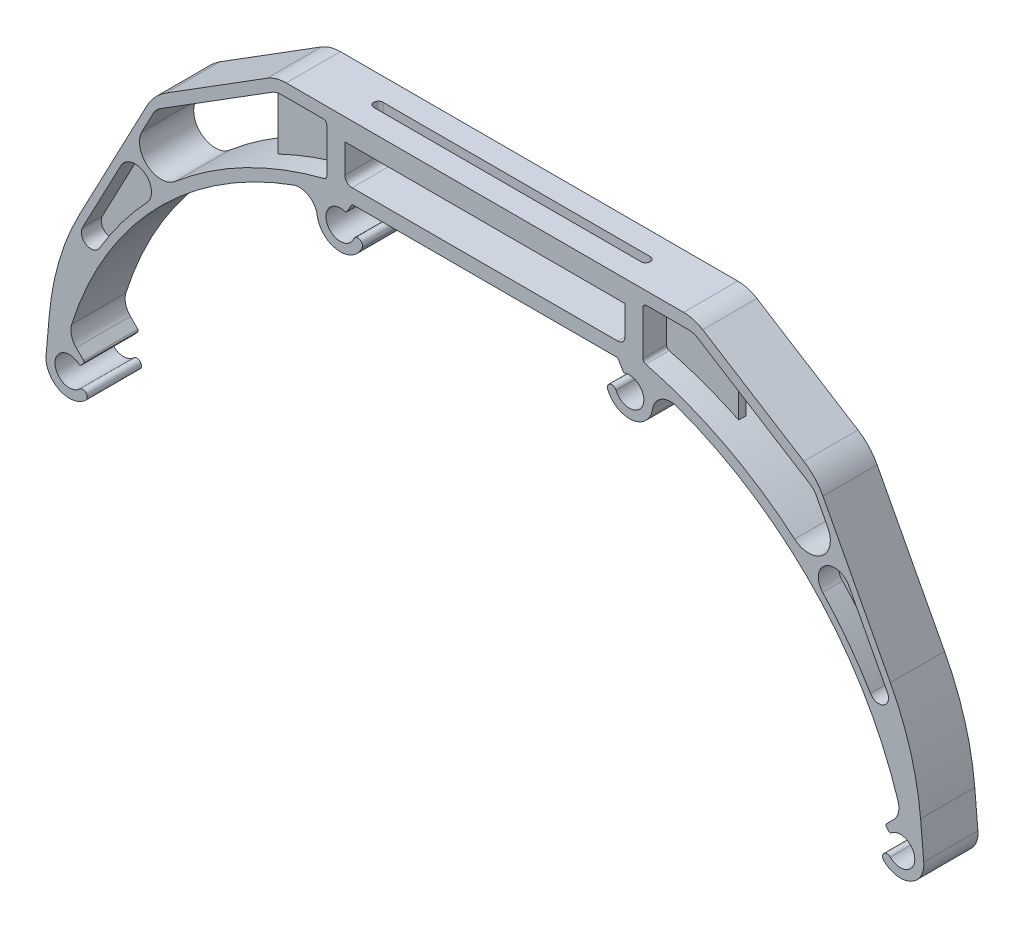
from build123d import *

# Parameters (mm, degrees)
EXTRUDE_7_DEPTH     = 15
CUT_EXTRUDE_1_DEPTH = 257.870857521
RIB_4_REACH         = 258.542
SKETCH_7_WALL_W     = 532.538559092
SKETCH_7_WALL_H     = 2
RIB_5_REACH         = 258.542
SKETCH_8_WALL_W     = 532.538559092
SKETCH_8_WALL_H     = 2
CUT_EXTRUDE_2_DEPTH = 257.870857521
CUT_EXTRUDE_3_DEPTH = 10
CUT_EXTRUDE_4_DEPTH = 257.870857521
EXTRUDE_8_DEPTH     = 2


with BuildPart() as part:
    # 草图3 → 凸台-拉伸7 (new body)
    with BuildSketch(Plane.XY):
        with BuildLine():
            Line((226.107883645, 4.564084021), (228.1313581, 6.587558476))
            ThreePointArc((228.1313581, 6.587558476), (229.452157682, 8.933123872), (229.365360937, 11.623598716))
            ThreePointArc((229.365360937, 11.623598716), (202.204022959, 54.721265071), (157.336152658, 78.846383531))
            ThreePointArc((157.336152658, 78.846383531), (156.176241581, 79.053674225), (155, 79.123092382))
            Line((155, 79.123092382), (75, 79.123092382))
            ThreePointArc((75, 79.123092382), (73.823758419, 79.053674225), (72.663847342, 78.846383531))
            ThreePointArc((72.663847342, 78.846383531), (27.795977041, 54.721265071), (0.634639063, 11.623598716))
            ThreePointArc((0.634639063, 11.623598716), (0.547842318, 8.933123872), (1.8686419, 6.587558476))
            Line((1.8686419, 6.587558476), (3.892116355, 4.564084021))
            ThreePointArc((3.892116355, 4.564084021), (4.038087075, 4.232340324), (3.921585186, 3.889136825))
            Line((3.921585186, 3.889136825), (3.278797577, 3.123092382))
            ThreePointArc((3.278797577, 3.123092382), (2.939119693, 2.946368462), (2.574022538, 3.0617655))
            ThreePointArc((2.574022538, 3.0617655), (-3.997102919, -0.152211219), (2.799416849, -2.857142857))
            ThreePointArc((2.799416849, -2.857142857), (4.567091757, -2.875182235), (4.549052379, -4.642857143))
            ThreePointArc((4.549052379, -4.642857143), (-2.777041025, -5.876907618), (-6.475265538, 0.566512328))
            Line((-6.475265538, 0.566512328), (-5.60370811, 10.528459309))
            ThreePointArc((-5.60370811, 10.528459309), (-2.837136411, 25.169145871), (2.769030559, 38.974018703))
            Line((2.769030559, 38.974018703), (21.426225279, 74.356346003))
            ThreePointArc((21.426225279, 74.356346003), (23.699524873, 77.563248735), (26.727922901, 80.069425417))
            Line((26.727922901, 80.069425417), (54.688883256, 97.596110672))
            ThreePointArc((54.688883256, 97.596110672), (57.236866172, 98.733768292), (60, 99.123092382))
            Line((60, 99.123092382), (170, 99.123092382))
            ThreePointArc((170, 99.123092382), (172.763133828, 98.733768292), (175.311116744, 97.596110672))
            Line((175.311116744, 97.596110672), (203.272077099, 80.069425417))
            ThreePointArc((203.272077099, 80.069425417), (206.300475127, 77.563248735), (208.573774721, 74.356346003))
            Line((208.573774721, 74.356346003), (227.230969441, 38.974018703))
            ThreePointArc((227.230969441, 38.974018703), (232.837136411, 25.169145871), (235.60370811, 10.528459309))
            Line((235.60370811, 10.528459309), (236.475265538, 0.566512328))
            ThreePointArc((236.475265538, 0.566512328), (232.777041025, -5.876907618), (225.450947621, -4.642857143))
            ThreePointArc((225.450947621, -4.642857143), (225.432908243, -2.875182235), (227.200583151, -2.857142857))
            ThreePointArc((227.200583151, -2.857142857), (233.997102919, -0.152211219), (227.425977462, 3.0617655))
            ThreePointArc((227.425977462, 3.0617655), (227.060880307, 2.946368462), (226.721202423, 3.123092382))
            Line((226.721202423, 3.123092382), (226.078414814, 3.889136825))
            ThreePointArc((226.078414814, 3.889136825), (225.961912925, 4.232340324), (226.107883645, 4.564084021))
        make_face()
        with BuildLine():
            Line((155, 79.123092382), (151.5, 79.123092382))
            ThreePointArc((151.5, 79.123092382), (151.75, 79.056105084), (151.933012702, 78.873092382))
            Line((151.933012702, 78.873092382), (153.208862747, 76.663255282))
            ThreePointArc((153.208862747, 76.663255282), (153.460925165, 76.447146931), (153.792778177, 76.436570515))
            ThreePointArc((153.792778177, 76.436570515), (158.62462258, 70.93131487), (151.301621364, 71.099282859))
            ThreePointArc((151.301621364, 71.099282859), (149.669687564, 71.778835706), (148.990134717, 70.146901906))
            ThreePointArc((148.990134717, 70.146901906), (155.784690615, 66.170630787), (161.428180194, 71.659505648))
            ThreePointArc((161.428180194, 71.659505648), (163.815160833, 75.214538736), (168.0781083, 75.6185384))
            ThreePointArc((168.0781083, 75.6185384), (162.752422297, 77.383187743), (157.336152658, 78.846383531))
            ThreePointArc((157.336152658, 78.846383531), (156.176241581, 79.053674225), (155, 79.123092382))
        make_face()
        with BuildLine():
            ThreePointArc((72.663847342, 78.846383531), (67.247577703, 77.383187743), (61.9218917, 75.6185384))
            ThreePointArc((61.9218917, 75.6185384), (66.184839167, 75.214538736), (68.571819806, 71.659505648))
            ThreePointArc((68.571819806, 71.659505648), (74.215309385, 66.170630787), (81.009865283, 70.146901906))
            ThreePointArc((81.009865283, 70.146901906), (80.330312436, 71.778835706), (78.698378636, 71.099282859))
            ThreePointArc((78.698378636, 71.099282859), (71.37537742, 70.93131487), (76.207221823, 76.436570515))
            ThreePointArc((76.207221823, 76.436570515), (76.539074835, 76.447146931), (76.791137253, 76.663255282))
            Line((76.791137253, 76.663255282), (78.066987298, 78.873092382))
            ThreePointArc((78.066987298, 78.873092382), (78.25, 79.056105084), (78.5, 79.123092382))
            Line((78.5, 79.123092382), (75, 79.123092382))
            ThreePointArc((75, 79.123092382), (73.823758419, 79.053674225), (72.663847342, 78.846383531))
        make_face()
    extrude(amount=EXTRUDE_7_DEPTH)

    # 草图6 → 切除-拉伸1 (cut, through all)
    with BuildSketch(Plane.XY.offset(15)):
        with BuildLine():
            ThreePointArc((58.67439973, 95.652604272), (57.292832816, 95.457942227), (56.018841358, 94.889113416))
            Line((56.018841358, 94.889113416), (51.236866172, 91.891642195))
            Line((51.236866172, 91.891642195), (51.236866172, 74.437432673))
            ThreePointArc((51.236866172, 74.437432673), (60.685741856, 78.429836873), (70.484678821, 81.463214092))
            ThreePointArc((70.484678821, 81.463214092), (71.026743583, 81.818757299), (71.236866172, 82.432022066))
            Line((71.236866172, 82.432022066), (71.236866172, 94.652604272))
            ThreePointArc((71.236866172, 94.652604272), (70.943972953, 95.359711053), (70.236866172, 95.652604272))
            Line((70.236866172, 95.652604272), (58.67439973, 95.652604272))
        make_face()
        with BuildLine():
            Line((51.236866172, 74.437432673), (51.236866172, 91.891642195))
            Line((51.236866172, 91.891642195), (25.036895933, 75.468793115))
            ThreePointArc((25.036895933, 75.468793115), (24.027429924, 74.633400887), (23.269663392, 73.56443331))
            Line((23.269663392, 73.56443331), (20.075243888, 67.506395211))
            ThreePointArc((20.075243888, 67.506395211), (21.629779543, 60.026321447), (29.268885543, 60.136521861))
            ThreePointArc((29.268885543, 60.136521861), (39.796372927, 67.988222639), (51.236866172, 74.437432673))
        make_face()
        with BuildLine():
            Line((178.763133828, 74.437432673), (178.763133828, 91.891642195))
            Line((178.763133828, 91.891642195), (173.981158642, 94.889113416))
            ThreePointArc((173.981158642, 94.889113416), (172.707167184, 95.457942227), (171.32560027, 95.652604272))
            Line((171.32560027, 95.652604272), (159.763133828, 95.652604272))
            ThreePointArc((159.763133828, 95.652604272), (159.056027047, 95.359711053), (158.763133828, 94.652604272))
            Line((158.763133828, 94.652604272), (158.763133828, 82.432022066))
            ThreePointArc((158.763133828, 82.432022066), (158.973256417, 81.818757299), (159.515321179, 81.463214092))
            ThreePointArc((159.515321179, 81.463214092), (169.314258144, 78.429836873), (178.763133828, 74.437432673))
        make_face()
        with BuildLine():
            Line((204.963104067, 75.468793115), (178.763133828, 91.891642195))
            Line((178.763133828, 91.891642195), (178.763133828, 74.437432673))
            ThreePointArc((178.763133828, 74.437432673), (190.203627073, 67.988222639), (200.731114457, 60.136521861))
            ThreePointArc((200.731114457, 60.136521861), (208.370220457, 60.026321447), (209.924756112, 67.506395211))
            Line((209.924756112, 67.506395211), (206.730336608, 73.56443331))
            ThreePointArc((206.730336608, 73.56443331), (205.972570076, 74.633400887), (204.963104067, 75.468793115))
        make_face()
    extrude(amount=-CUT_EXTRUDE_1_DEPTH, mode=Mode.SUBTRACT)

    # 草图7 wall → 筋4 (add, up to next)
    with BuildSketch(Plane(origin=(51.236866172, 83.164537434, 7.5), x_dir=(0, -1, 0), z_dir=(1, 0, 0)), mode=Mode.PRIVATE) as rib_4_sk1:
        Rectangle(SKETCH_7_WALL_W, SKETCH_7_WALL_H)
    rib_4_tool1 = extrude(rib_4_sk1.sketch, amount=RIB_4_REACH, mode=Mode.PRIVATE) - part.part
    add(rib_4_tool1.solids().sort_by_distance((51.236866172, 83.164537434, 7.5))[0])

    # 草图8 wall → 筋5 (add, up to next)
    with BuildSketch(Plane(origin=(178.763133828, 83.164537434, 7.5), x_dir=(0, -1, 0), z_dir=(1, 0, 0)), mode=Mode.PRIVATE) as rib_5_sk1:
        Rectangle(SKETCH_8_WALL_W, SKETCH_8_WALL_H)
    rib_5_tool1 = extrude(rib_5_sk1.sketch, amount=-RIB_5_REACH, mode=Mode.PRIVATE) - part.part
    add(rib_5_tool1.solids().sort_by_distance((178.763133828, 83.164537434, 7.5))[0])

    # 草图9 → 切除-拉伸2 (cut, through all)
    with BuildSketch(Plane.XY.offset(15)):
        with BuildLine():
            Line((76.236866172, 93.123092382), (153.763133828, 93.123092382))
            Line((153.763133828, 93.123092382), (153.763133828, 85.123092382))
            ThreePointArc((153.763133828, 85.123092382), (153.177347391, 83.70887882), (151.763133828, 83.123092382))
            Line((151.763133828, 83.123092382), (78.236866172, 83.123092382))
            ThreePointArc((78.236866172, 83.123092382), (76.822652609, 83.70887882), (76.236866172, 85.123092382))
            Line((76.236866172, 85.123092382), (76.236866172, 93.123092382))
        make_face()
    extrude(amount=-CUT_EXTRUDE_2_DEPTH, mode=Mode.SUBTRACT)

    # 草图10 → 切除-拉伸3 (cut)
    with BuildSketch(Plane(origin=(0, 99.123092382, 0), x_dir=(1, 0, 0), z_dir=(0, 1, 0))):
        with BuildLine():
            Line((152, -6.25), (78, -6.25))
            ThreePointArc((78, -6.25), (76.75, -7.5), (78, -8.75))
            Line((78, -8.75), (152, -8.75))
            ThreePointArc((152, -8.75), (153.25, -7.5), (152, -6.25))
        make_face()
    extrude(amount=-CUT_EXTRUDE_3_DEPTH, mode=Mode.SUBTRACT)

    # 草图11 → 切除-拉伸4 (cut, through all)
    with BuildSketch(Plane.XY.offset(15)):
        with BuildLine():
            Line((14.222124531, 56.406281397), (3.59559655, 36.253664848))
            ThreePointArc((3.59559655, 36.253664848), (4.660529559, 32.65450196), (8.285133372, 33.629336818))
            ThreePointArc((8.285133372, 33.629336818), (14.408945847, 42.791561817), (21.485479078, 51.239645835))
            ThreePointArc((21.485479078, 51.239645835), (20.80587389, 57.973042706), (14.222124531, 56.406281397))
        make_face()
        with BuildLine():
            Line((215.777875469, 56.406281397), (226.40440345, 36.253664848))
            ThreePointArc((226.40440345, 36.253664848), (225.339470441, 32.65450196), (221.714866628, 33.629336818))
            ThreePointArc((221.714866628, 33.629336818), (215.591054153, 42.791561817), (208.514520922, 51.239645835))
            ThreePointArc((208.514520922, 51.239645835), (209.19412611, 57.973042706), (215.777875469, 56.406281397))
        make_face()
    extrude(amount=-CUT_EXTRUDE_4_DEPTH, mode=Mode.SUBTRACT)

    # 草图12 → 凸台-拉伸8 (add, symmetric)
    with BuildSketch(Plane.XY.offset(7.5)):
        with BuildLine():
            Line((215.777875469, 56.406281397), (226.40440345, 36.253664848))
            ThreePointArc((226.40440345, 36.253664848), (225.339470441, 32.65450196), (221.714866628, 33.629336818))
            ThreePointArc((221.714866628, 33.629336818), (215.591054153, 42.791561817), (208.514520922, 51.239645835))
            ThreePointArc((208.514520922, 51.239645835), (209.19412611, 57.973042706), (215.777875469, 56.406281397))
        make_face()
        with BuildLine():
            Line((14.222124531, 56.406281397), (3.59559655, 36.253664848))
            ThreePointArc((3.59559655, 36.253664848), (4.660529559, 32.65450196), (8.285133372, 33.629336818))
            ThreePointArc((8.285133372, 33.629336818), (14.408945847, 42.791561817), (21.485479078, 51.239645835))
            ThreePointArc((21.485479078, 51.239645835), (20.80587389, 57.973042706), (14.222124531, 56.406281397))
        make_face()
    extrude(amount=EXTRUDE_8_DEPTH, both=True)


solid = part.part
